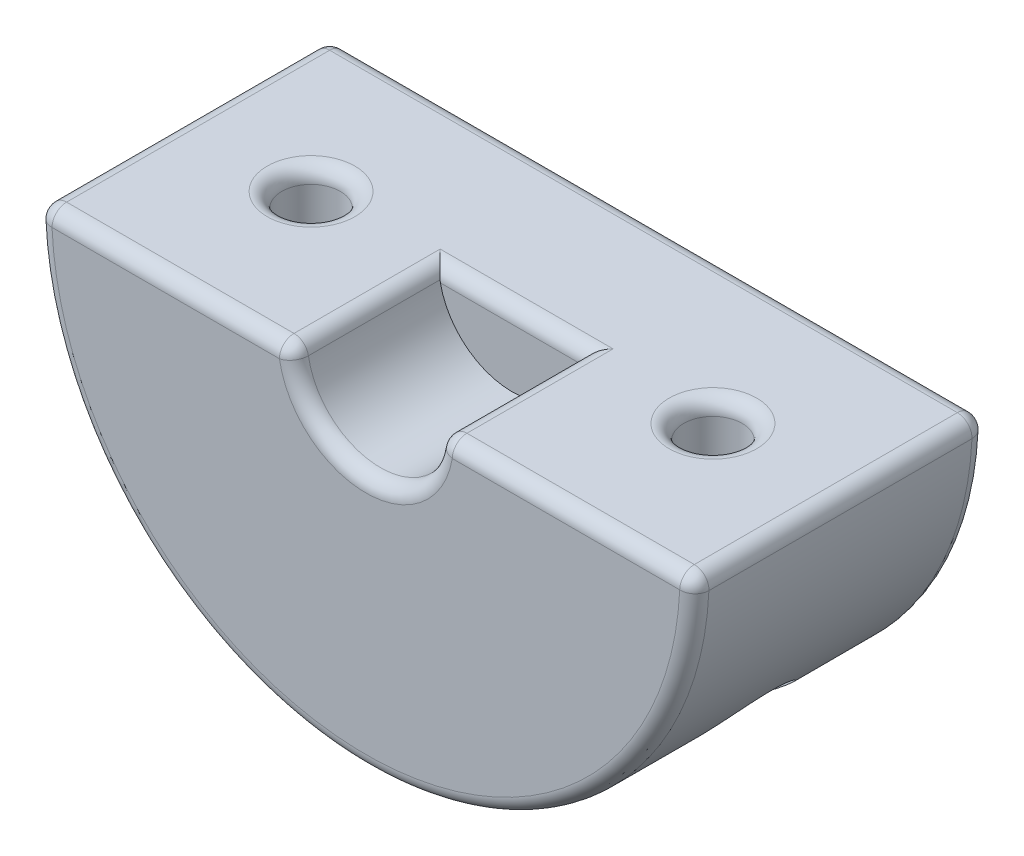
from build123d import *

# Parameters (mm, degrees)
BOSS_EXTRUDE1_DEPTH = 10
SKETCH2_R           = 5
CUT_EXTRUDE1_DEPTH  = 10
SKETCH3_R           = 2
CUT_EXTRUDE2_DEPTH  = 23.5
SKETCH4_R           = 4
CUT_EXTRUDE3_DEPTH  = 12
FILLET1_R           = 1
FILLET2_R           = 0.5


with BuildPart() as part:
    # Sketch1 → Boss-Extrude1 (new body, symmetric)
    with BuildSketch(Plane.XY):
        with BuildLine():
            Line((-22.5, 0), (22.5, 0))
            ThreePointArc((22.5, 0), (0, -22.5), (-22.5, 0))
        make_face()
    extrude(amount=BOSS_EXTRUDE1_DEPTH, both=True)

    # Sketch2 → Cut-Extrude1 (cut)
    with BuildSketch(Plane.XY.offset(10)):
        Circle(SKETCH2_R)
    extrude(amount=-CUT_EXTRUDE1_DEPTH, mode=Mode.SUBTRACT)

    # Sketch3 → Cut-Extrude2 (cut, through all)
    with BuildSketch(Plane(origin=(0, 0, 0), x_dir=(1, 0, 0), z_dir=(0, 1, 0))):
        with Locations((13.75, 0)):
            Circle(SKETCH3_R)
        with Locations((-13.75, 0)):
            Circle(SKETCH3_R)
    extrude(amount=-CUT_EXTRUDE2_DEPTH, mode=Mode.SUBTRACT)

    # Sketch4 → Cut-Extrude3 (cut)
    with BuildSketch(Plane(origin=(0, -25, 0), x_dir=(1, 0, 0), z_dir=(0, 1, 0))):
        with Locations((13.75, 0)):
            Circle(SKETCH4_R)
        with Locations((-13.75, 0)):
            Circle(SKETCH4_R)
    extrude(amount=CUT_EXTRUDE3_DEPTH, mode=Mode.SUBTRACT)

    # Fillet1
    fillet1_edges = [part.edges().sort_by_distance(p)[0] for p in [
        (0, 0, 0),
        (5, 0, 5),
        (-5, 0, 5),
        (11.75, 0, 0),
        (-15.75, 0, 0),
        (0, 0, -10),
        (0, -22.5, -10),
        (-22.5, 0, 0),
        (22.5, 0, 0),
        (0, -22.5, 10),
        (13.75, 0, 10),
        (-13.75, 0, 10),
        (0, -5, 10),
    ]]
    fillet(fillet1_edges, radius=FILLET1_R)

    # Fillet2
    fillet2_edges = [part.edges().sort_by_distance(p)[0] for p in [
        (9.75, -13, 0),
        (11.75, -13, 0),
        (-17.75, -13, 0),
        (-15.75, -13, 0),
    ]]
    fillet(fillet2_edges, radius=FILLET2_R)


solid = part.part
